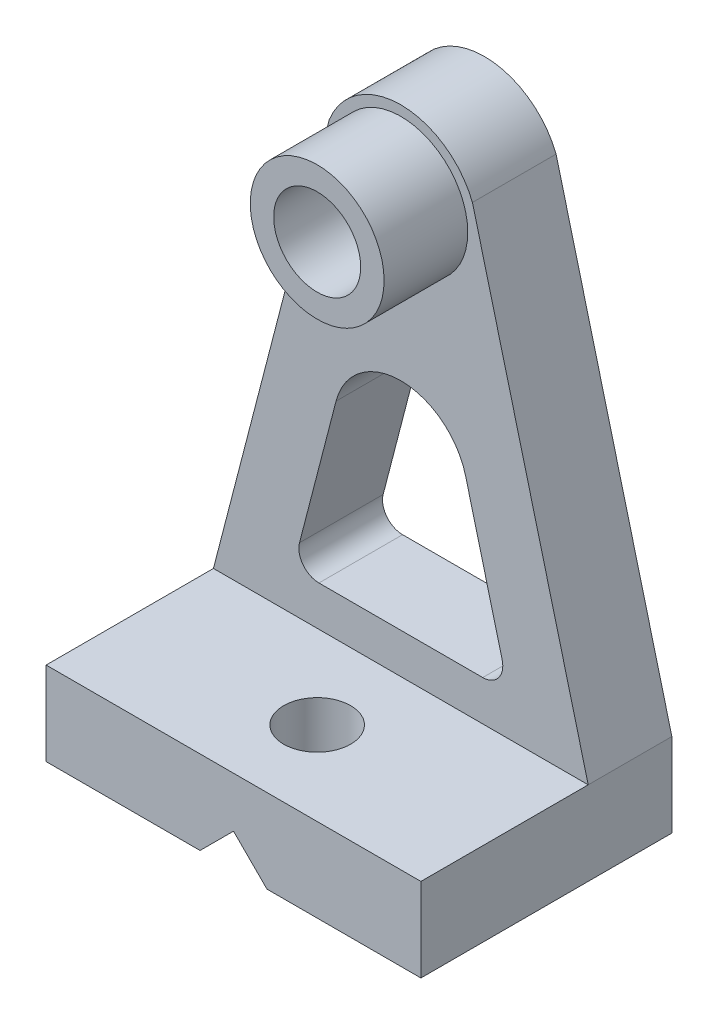
from build123d import *

# Parameters (mm, degrees)
IZIM1_R                          = 20
IZIM1_R_2                        = 13
Y_KSEKLIK_EKSTR_ZYON1_DEPTH      = 25
IZIM2_W                          = 75
IZIM2_H                          = 25
Y_KSEKLIK_EKSTR_ZYON3_DEPTH      = 55.415897
Y_KSEKLIK_EKSTR_ZYON3_DEPTH_BACK = 56.584103
KES_EKSTR_ZYON1_DEPTH            = 76
IZIM5_R                          = 10
KES_EKSTR_ZYON2_DEPTH            = 26
KES_EKSTR_ZYON3_DEPTH            = 26
IZIM1_7_R                        = 20
IZIM1_7_R_2                      = 13
Y_KSEKLIK_EKSTR_ZYON6_DEPTH      = 50


with BuildPart() as part:
    # Çizim1 → Yükseklik-Ekstrüzyon1 (new body)
    with BuildSketch(Plane.XY):
        with BuildLine():
            Line((20.815714115, 93.071898447), (55.415896847, -40.357088497))
            Line((55.415896847, -40.357088497), (-56.584103153, -40.357088497))
            Line((-56.584103153, -40.357088497), (-21.983920421, 93.071898447))
            ThreePointArc((-21.983920421, 93.071898447), (-0.584103153, 107.642911503), (20.815714115, 93.071898447))
        make_face()
        with Locations((-0.584103153, 84.642911503)):
            Circle(IZIM1_R, mode=Mode.SUBTRACT)
        with Locations((-0.584103153, 84.642911503)):
            Circle(IZIM1_R)
        with Locations((-0.584103153, 84.642911503)):
            Circle(IZIM1_R_2, mode=Mode.SUBTRACT)
    extrude(amount=Y_KSEKLIK_EKSTR_ZYON1_DEPTH)

    # Çizim2 → Yükseklik-Ekstrüzyon3 (add, two sides)
    with BuildSketch(Plane(origin=(0, 0, 0), x_dir=(0, 0, -1), z_dir=(1, 0, 0))) as y_kseklik_ekstr_zyon3_sk:
        with Locations((-37.5, -52.857088497)):
            Rectangle(IZIM2_W, IZIM2_H)
    extrude(amount=Y_KSEKLIK_EKSTR_ZYON3_DEPTH)
    extrude(y_kseklik_ekstr_zyon3_sk.sketch, amount=-Y_KSEKLIK_EKSTR_ZYON3_DEPTH_BACK)

    # Çizim3 → Kes-Ekstrüzyon1 (cut, through all)
    with BuildSketch(Plane.XY.offset(75)):
        Polygon((-10.584103153, -65.357088497), (-0.584103153, -55.357088497), (9.415896847, -65.357088497), align=None)
    extrude(amount=-KES_EKSTR_ZYON1_DEPTH, mode=Mode.SUBTRACT)

    # Çizim5 → Kes-Ekstrüzyon2 (cut, through all)
    with BuildSketch(Plane(origin=(0, -40.357088497, 0), x_dir=(1, 0, 0), z_dir=(0, 1, 0))):
        with Locations((-0.584103153, -50)):
            Circle(IZIM5_R)
    extrude(amount=-KES_EKSTR_ZYON2_DEPTH, mode=Mode.SUBTRACT)

    # Çizim8 → Kes-Ekstrüzyon3 (cut, through all)
    with BuildSketch(Plane.XY.offset(25)):
        with BuildLine():
            Line((-19.943777352, 21.2621788), (-30.864373198, -20.851010365))
            ThreePointArc((-30.864373198, -20.851010365), (-29.801809113, -26.028840886), (-25.056470938, -28.357088497))
            Line((-25.056470938, -28.357088497), (23.888264632, -28.357088497))
            ThreePointArc((23.888264632, -28.357088497), (28.633602807, -26.028840886), (29.696166892, -20.851010365))
            Line((29.696166892, -20.851010365), (18.775571046, 21.2621788))
            ThreePointArc((18.775571046, 21.2621788), (-0.584103153, 36.241918358), (-19.943777352, 21.2621788))
        make_face()
    extrude(amount=-KES_EKSTR_ZYON3_DEPTH, mode=Mode.SUBTRACT)

    # Çizim1<7> → Yükseklik-Ekstrüzyon6 (add)
    with BuildSketch(Plane.XY):
        with Locations((-0.584103153, 84.642911503)):
            Circle(IZIM1_7_R)
        with Locations((-0.584103153, 84.642911503)):
            Circle(IZIM1_7_R_2, mode=Mode.SUBTRACT)
    extrude(amount=Y_KSEKLIK_EKSTR_ZYON6_DEPTH)


solid = part.part
